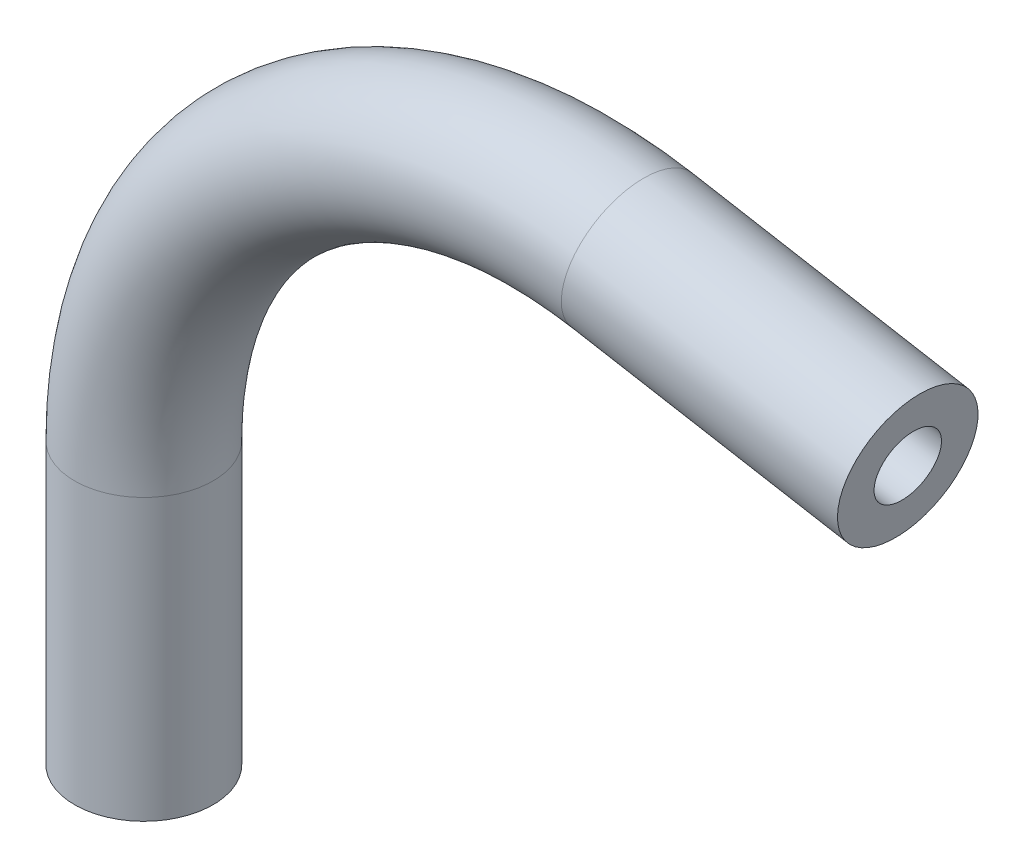
from build123d import *

# Parameters (mm, degrees)
SKETCH2_R   = 3.175
SKETCH2_R_2 = 1.524


with BuildPart() as part:
    # Sweep1: sweep along a path in Sketch1
    with BuildLine(Plane.XY) as sweep1_path:
        Line((0, -14.379411942), (0, -1.522317881))
        ThreePointArc((0, -1.522317881), (6.804896035, 13.070828761), (22.357997785, 17.238269814))
        Line((22.357997785, 17.238269814), (35.019763697, 15.00565886))
    # Sketch2 → Sweep1 (sweep)
    with BuildSketch(Plane(origin=(35.019763697, 15.00565886, 0), x_dir=(0, 0, -1), z_dir=(0.984807753, -0.173648178, 0))):
        Circle(SKETCH2_R)
        Circle(SKETCH2_R_2, mode=Mode.SUBTRACT)
    sweep(path=sweep1_path.line)


solid = part.part
